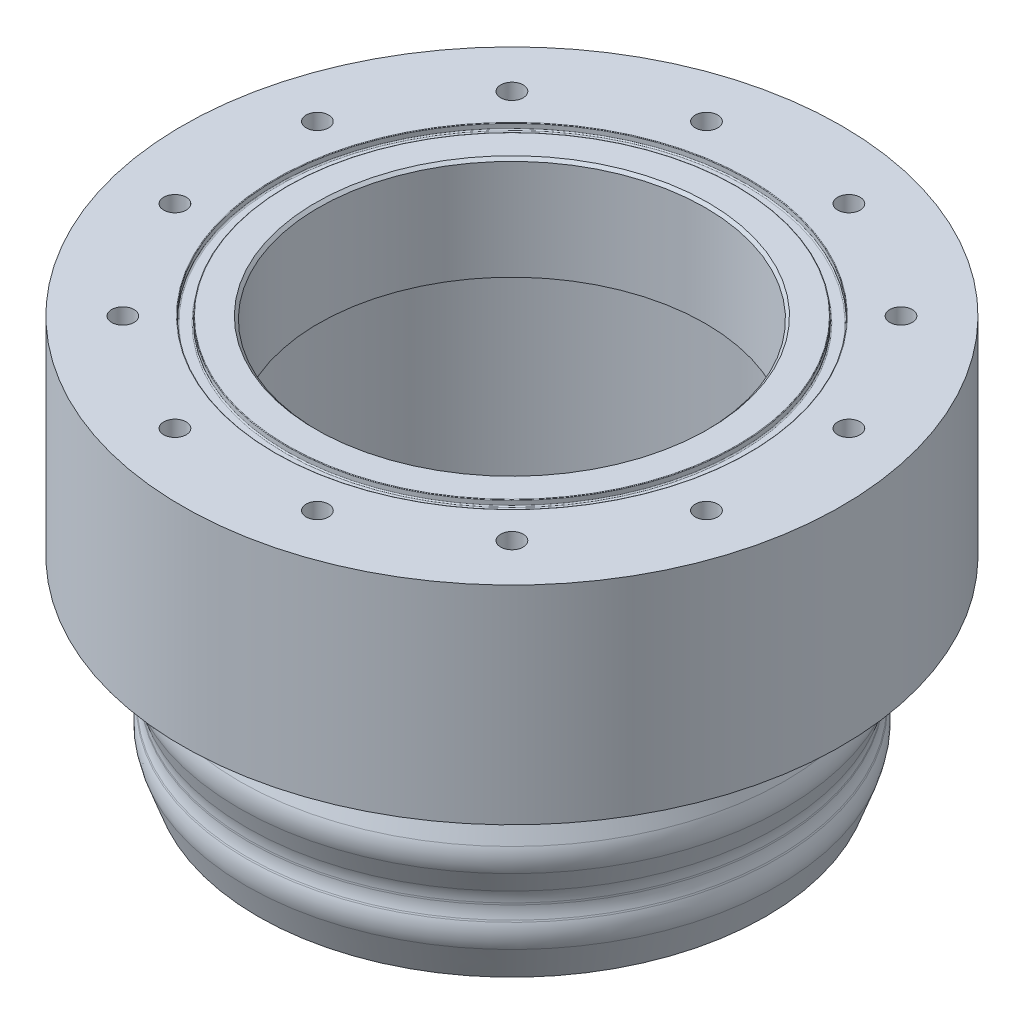
from build123d import *

# Parameters (mm, degrees)
ASSEMBLY_BOLT_INSERT_DIAMETER_R = 2.4892
ASSEMBLY_BOLT_INSERT_CUT_DEPTH  = 21.59
ASSEMBLY_BOLTS_COUNT            = 12
FILLET1_R                       = 7.62
FILLET2_R                       = 2.54
FILLET3_R                       = 7.62
FILLET7_R                       = 7.62
CHAMFER1_SIZE                   = 0.635


with BuildPart() as part:
    # Flange profile → Flange (revolve)
    with BuildSketch(Plane.XY):
        with BuildLine():
            Line((-42.8625, 22.86), (-42.8625, 0))
            Line((-42.8625, 0), (-55.7276, 0))
            Line((-55.7276, 0), (-55.7276, -64.266896465))
            Line((-55.7276, -64.266896465), (-56.2356, -64.266896465))
            Line((-56.2356, -64.266896465), (-59.7916, -54.496866762))
            Line((-59.7916, -54.496866762), (-58.2676, -50.309711174))
            Line((-58.2676, -50.309711174), (-58.2676, -47.236311174))
            Line((-58.2676, -47.236311174), (-61.3156, -38.862))
            Line((-61.3156, -38.862), (-58.2676, -30.487688826))
            Line((-58.2676, -30.487688826), (-58.2676, -23.151254335))
            Line((-58.2676, -23.151254335), (-73.025, -23.151254335))
            Line((-73.025, -23.151254335), (-73.025, 22.86))
            Line((-73.025, 22.86), (-52.5653, 22.86))
            ThreePointArc((-52.5653, 22.86), (-52.475497439, 22.822802561), (-52.4383, 22.733))
            Line((-52.4383, 22.733), (-52.4383, 21.7932))
            ThreePointArc((-52.4383, 21.7932), (-52.363905122, 21.613594878), (-52.1843, 21.5392))
            Line((-52.1843, 21.5392), (-50.1269, 21.5392))
            ThreePointArc((-50.1269, 21.5392), (-49.947294878, 21.613594878), (-49.8729, 21.7932))
            Line((-49.8729, 21.7932), (-49.8729, 22.733))
            ThreePointArc((-49.8729, 22.733), (-49.835702561, 22.822802561), (-49.7459, 22.86))
            Line((-49.7459, 22.86), (-42.8625, 22.86))
        make_face()
    revolve(axis=Axis((0, 0, 0), (0, 1, 0)))

    # Assembly Bolt Insert Diameter → Assembly Bolt Insert Cut (cut)
    with BuildSketch(Plane(origin=(0, 22.86, 0), x_dir=(1, 0, 0), z_dir=(0, 1, 0))):
        with Locations((-58.882838371, 15.777608989)):
            Circle(ASSEMBLY_BOLT_INSERT_DIAMETER_R)
    assembly_bolt_insert_cut = extrude(amount=-ASSEMBLY_BOLT_INSERT_CUT_DEPTH, mode=Mode.SUBTRACT)

    # Assembly Bolts: Assembly Bolt Insert Cut ×12 about axis
    assembly_bolts_axis = Axis((0, 0, 0), (0, -1, 0))
    for i in range(1, ASSEMBLY_BOLTS_COUNT):
        add(assembly_bolt_insert_cut.rotate(assembly_bolts_axis, i * 360 / ASSEMBLY_BOLTS_COUNT), mode=Mode.SUBTRACT)

    # Fillet1
    fillet1_edges = [part.edges().sort_by_distance(p)[0] for p in [
        (61.3156, -38.862, 0),
    ]]
    fillet(fillet1_edges, radius=FILLET1_R)

    # Fillet2
    fillet2_edges = [part.edges().sort_by_distance(p)[0] for p in [
        (58.2676, -23.151254335, 0),
        (55.7276, 0, 0),
    ]]
    fillet(fillet2_edges, radius=FILLET2_R)

    # Fillet3
    fillet3_edges = [part.edges().sort_by_distance(p)[0] for p in [
        (59.7916, -54.496866762, 0),
    ]]
    fillet(fillet3_edges, radius=FILLET3_R)

    # Fillet7
    fillet7_edges = [part.edges().sort_by_distance(p)[0] for p in [
        (58.2676, -50.309711174, 0),
        (58.2676, -47.236311174, 0),
        (58.2676, -30.487688826, 0),
    ]]
    fillet(fillet7_edges, radius=FILLET7_R)

    # Chamfer1
    chamfer1_edges = [part.edges().sort_by_distance(p)[0] for p in [
        (42.8625, 22.86, 0),
    ]]
    chamfer(chamfer1_edges, length=CHAMFER1_SIZE)


solid = part.part
